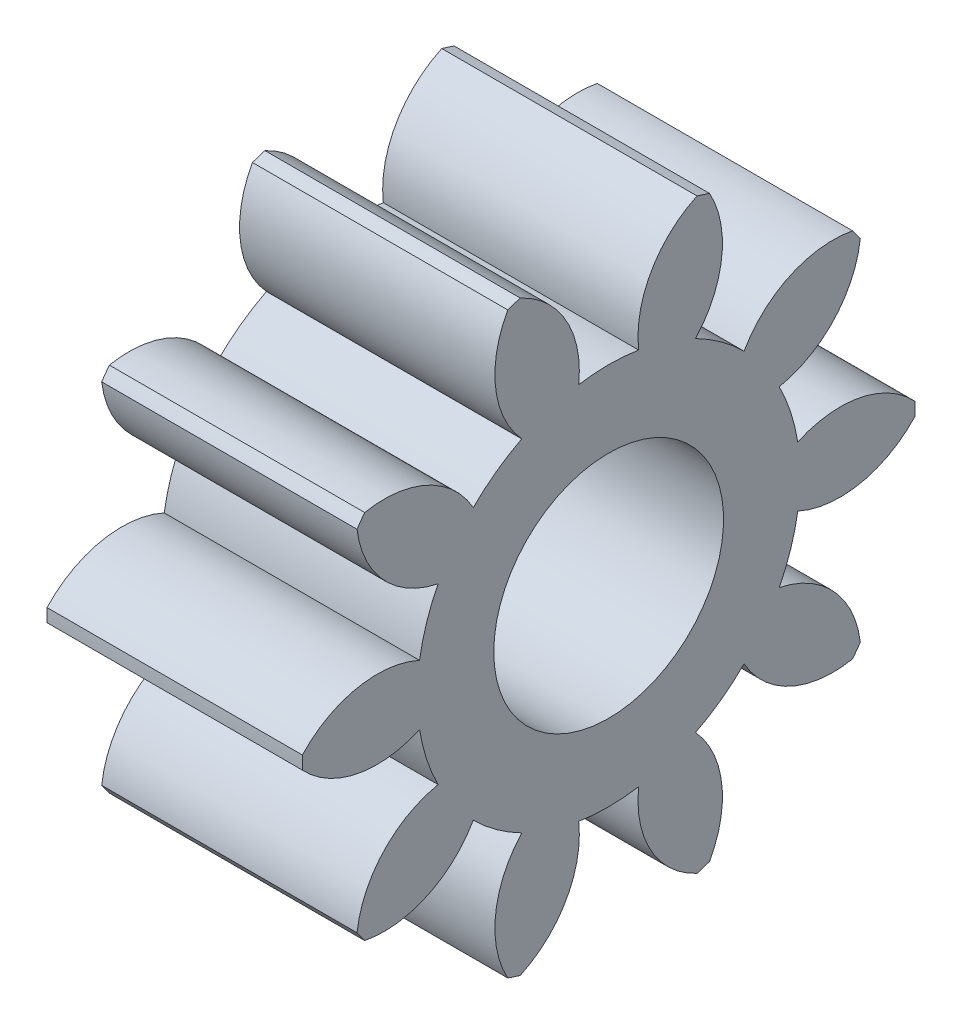
from build123d import *

# Parameters (mm, degrees)
BASPROSKE_W     = 10
BASPROSKE_H     = 12
TOOTHCUT_DEPTH  = 20.697715604
TEETHCUTS_COUNT = 10
TEETHCUTS_ANGLE = 324
BORSKE_R        = 4.5
BORE_DEPTH      = 50.0000508


with BuildPart() as part:
    # BasProSke → Base-Revolve (revolve)
    with BuildSketch(Plane(origin=(0, 0, 0), x_dir=(1, 0, 0), z_dir=(0, 1, 0)), mode=Mode.PRIVATE) as base_revolve_sk:
        with Locations((5, 6)):
            Rectangle(BASPROSKE_W, BASPROSKE_H)
    revolve(base_revolve_sk.sketch.rotate(Axis((-10, 0, 0), (1, 0, 0)), 180), axis=Axis((-10, 0, 0), (1, 0, 0)))

    # TooCutSke → ToothCut (cut, through all)
    with BuildSketch(Plane(origin=(0, 0, 0), x_dir=(0, 0, -1), z_dir=(1, 0, 0))):
        with BuildLine():
            ThreePointArc((1.173662691, 7.406586048), (0, 7.499), (-1.173662691, 7.406586048))
            ThreePointArc((-1.173662691, 7.406586048), (-1.668191438, 9.834565786), (-3.497907776, 11.50542856))
            ThreePointArc((-3.497907776, 11.50542856), (0, 12.0254), (3.497907776, 11.50542856))
            ThreePointArc((3.497907776, 11.50542856), (1.668191438, 9.834565786), (1.173662691, 7.406586048))
        make_face()
    toothcut = extrude(amount=TOOTHCUT_DEPTH, mode=Mode.SUBTRACT)

    # TeethCuts: ToothCut ×10 about axis
    teethcuts_axis = Axis((-10, 0, 0), (1, 0, 0))
    for i in range(1, TEETHCUTS_COUNT):
        add(toothcut.rotate(teethcuts_axis, i * TEETHCUTS_ANGLE / (TEETHCUTS_COUNT - 1)), mode=Mode.SUBTRACT)

    # BorSke → Bore (cut, symmetric)
    with BuildSketch(Plane(origin=(0, 0, 0), x_dir=(0, 0, -1), z_dir=(1, 0, 0))):
        with Locations(Location((0, 0, 0), (0, 0, 180))):
            Circle(BORSKE_R)
    extrude(amount=BORE_DEPTH, both=True, mode=Mode.SUBTRACT)


solid = part.part
